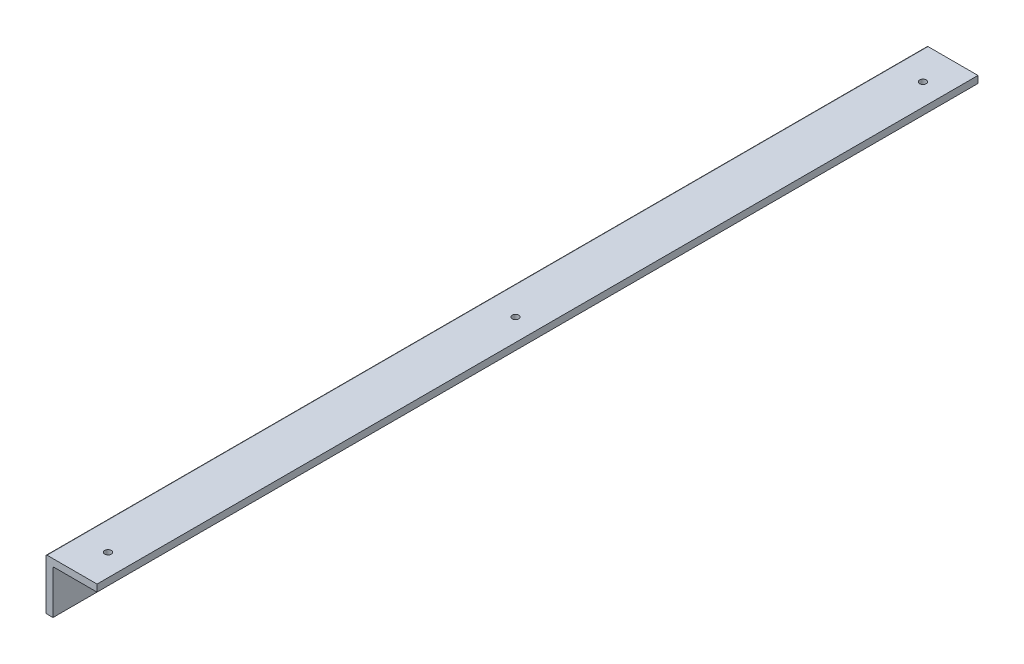
from build123d import *

# Parameters (mm, degrees)
SKETCH1_W           = 3.175
SKETCH1_H           = 20
BOSS_EXTRUDE1_DEPTH = 400
SKETCH3_R           = 1.5
CUT_EXTRUDE1_DEPTH  = 400
SKETCH4_R           = 1.5
CUT_EXTRUDE2_DEPTH  = 400
FILLET1_R           = 0.5


with BuildPart() as part:
    # Sketch1 → Boss-Extrude1 (new body)
    with BuildSketch(Plane.XY):
        with Locations((1.5875, 10)):
            Rectangle(SKETCH1_W, SKETCH1_H)
        Polygon((0, 23.175), (0, 20), (3.175, 20), (23.175, 20), (23.175, 23.175), align=None)
    extrude(amount=BOSS_EXTRUDE1_DEPTH)

    # Sketch3 → Cut-Extrude1 (cut)
    with BuildSketch(Plane(origin=(0, 23.175, 0), x_dir=(1, 0, 0), z_dir=(0, 1, 0))):
        with Locations((13.175, -200)):
            Circle(SKETCH3_R)
        with Locations((13.175, -385)):
            Circle(SKETCH3_R)
        with Locations((13.175, -15)):
            Circle(SKETCH3_R)
    extrude(amount=-CUT_EXTRUDE1_DEPTH, mode=Mode.SUBTRACT)

    # Sketch4 → Cut-Extrude2 (cut)
    with BuildSketch(Plane(origin=(3.175, 0, 0), x_dir=(0, 0, -1), z_dir=(1, 0, 0))):
        with Locations((-385, 10)):
            Circle(SKETCH4_R)
        with Locations((-200, 10)):
            Circle(SKETCH4_R)
        with Locations((-15, 10)):
            Circle(SKETCH4_R)
    extrude(amount=-CUT_EXTRUDE2_DEPTH, mode=Mode.SUBTRACT)

    # Fillet1
    fillet1_edges = [part.edges().sort_by_distance(p)[0] for p in [
        (0, 23.175, 200),
        (3.175, 20, 200),
    ]]
    fillet(fillet1_edges, radius=FILLET1_R)


solid = part.part
